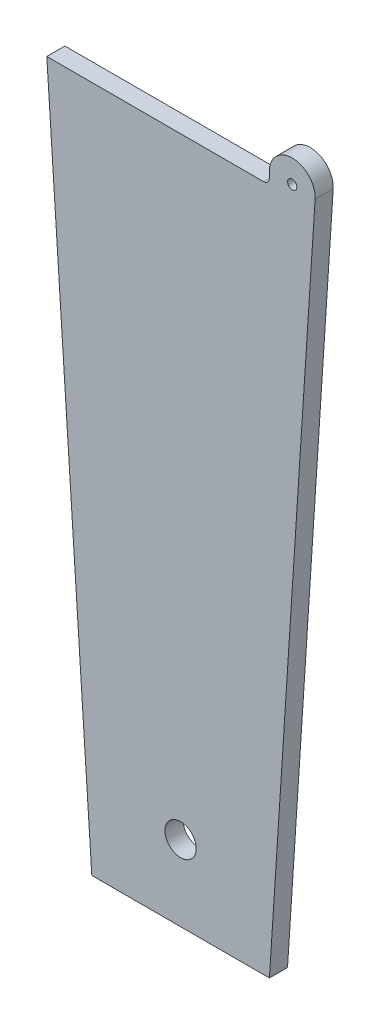
from build123d import *

# Parameters (mm, degrees)
EXTRUDE1_DEPTH     = 1.56
SKETCH2_R          = 1.3462
CUT_EXTRUDE2_DEPTH = 2.56
SKETCH3_R          = 0.396875
EXTRUDE2_DEPTH     = 1.56
FILLET1_R          = 0.5


with BuildPart() as part:
    # Sketch1 → Extrude1 (new body)
    with BuildSketch(Plane.XY):
        Polygon((-7.655500535, 35), (7.655500535, 35), (11.535673534, 94.2), (-11.535673534, 94.2), align=None)
    extrude(amount=EXTRUDE1_DEPTH)

    # Sketch2 → Cut-Extrude2 (cut, through all)
    with BuildSketch(Plane(origin=(2.513247729, -24.95744912, 1.56), x_dir=(1, 0, 0), z_dir=(0, 0, 1))):
        with Locations((-2.513247729, 66.45744912)):
            Circle(SKETCH2_R)
    extrude(amount=-CUT_EXTRUDE2_DEPTH, mode=Mode.SUBTRACT)

    # Sketch3 → Extrude2 (add)
    with BuildSketch(Plane.XY.offset(1.56)):
        with BuildLine():
            Line((11.535673534, 94.2), (7.646607283, 94.2))
            Line((7.646607283, 94.2), (7.646607283, 95.22402761))
            ThreePointArc((7.646607283, 95.22402761), (9.687231677, 97.19894204), (11.594321354, 95.094792832))
            Line((11.594321354, 95.094792832), (11.535673534, 94.2))
        make_face()
        with Locations((9.622579673, 95.22402761)):
            Circle(SKETCH3_R, mode=Mode.SUBTRACT)
    extrude(amount=-EXTRUDE2_DEPTH)

    # Fillet1
    fillet1_edges = [part.edges().sort_by_distance(p)[0] for p in [
        (7.646607283, 94.2, 0.78),
    ]]
    fillet(fillet1_edges, radius=FILLET1_R)


solid = part.part
